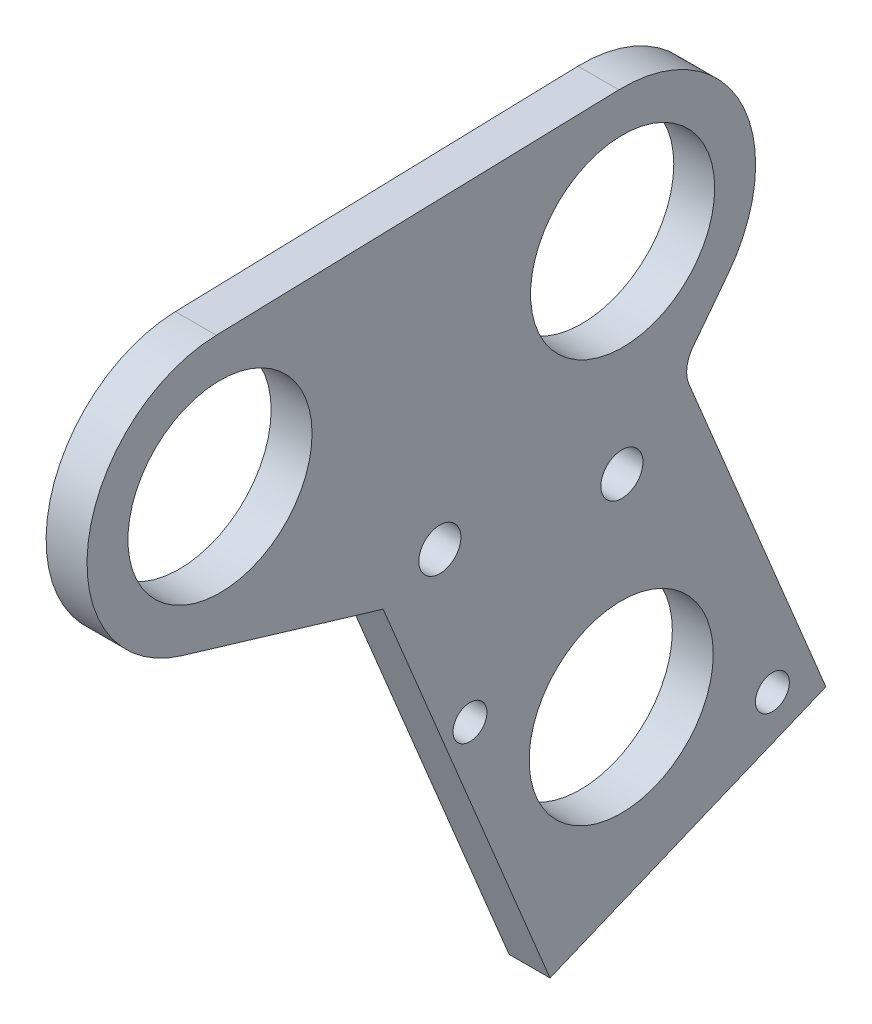
from build123d import *

# Parameters (mm, degrees)
SKETCH1_R           = 2.6289
SKETCH1_R_2         = 14.2875
SKETCH1_R_3         = 3.2639
BOSS_EXTRUDE1_DEPTH = 6.35
FILLET1_R           = 4.7625


with BuildPart() as part:
    # Sketch1 → Boss-Extrude1 (new body)
    with BuildSketch(Plane(origin=(0, 0, 0), x_dir=(0, 0, -1), z_dir=(1, 0, 0))):
        with BuildLine():
            Line((261.600661049, 84.883471899), (235.704081281, 147.403346332))
            Line((235.704081281, 147.403346332), (204.461245323, 156.764386521))
            ThreePointArc((204.461245323, 156.764386521), (189.925416447, 179.241173024), (209.807662792, 197.163018154))
            Line((209.807662792, 197.163018154), (241.790461139, 198.057364052))
            Line((241.790461139, 198.057364052), (272.292637552, 198.910306814))
            ThreePointArc((272.292637552, 198.910306814), (291.249324985, 187.666425791), (289.242335043, 165.717556793))
            Line((289.242335043, 165.717556793), (282.117070677, 156.43173152))
            Line((282.117070677, 156.43173152), (304.408641761, 102.615117992))
            Line((304.408641761, 102.615117992), (261.600661049, 84.883471899))
        make_face()
        with Locations((296.111966941, 106.051713243)):
            Circle(SKETCH1_R, mode=Mode.SUBTRACT)
        with Locations((249.178886841, 125.492031649)):
            Circle(SKETCH1_R, mode=Mode.SUBTRACT)
        with Locations((272.645426891, 115.771872446)):
            Circle(SKETCH1_R_2, mode=Mode.SUBTRACT)
        with Locations((210.384530747, 176.533582155)):
            Circle(SKETCH1_R_2, mode=Mode.SUBTRACT)
        with Locations((272.869505507, 178.280870816)):
            Circle(SKETCH1_R_2, mode=Mode.SUBTRACT)
        with Locations((272.757466199, 147.026371631)):
            Circle(SKETCH1_R_3, mode=Mode.SUBTRACT)
        with Locations((244.504033835, 151.048406008)):
            Circle(SKETCH1_R_3, mode=Mode.SUBTRACT)
    extrude(amount=BOSS_EXTRUDE1_DEPTH)

    # Fillet1
    fillet1_edges = [part.edges().sort_by_distance(p)[0] for p in [
        (3.175, 156.43173152, -282.117070677),
    ]]
    fillet(fillet1_edges, radius=FILLET1_R)


solid = part.part
